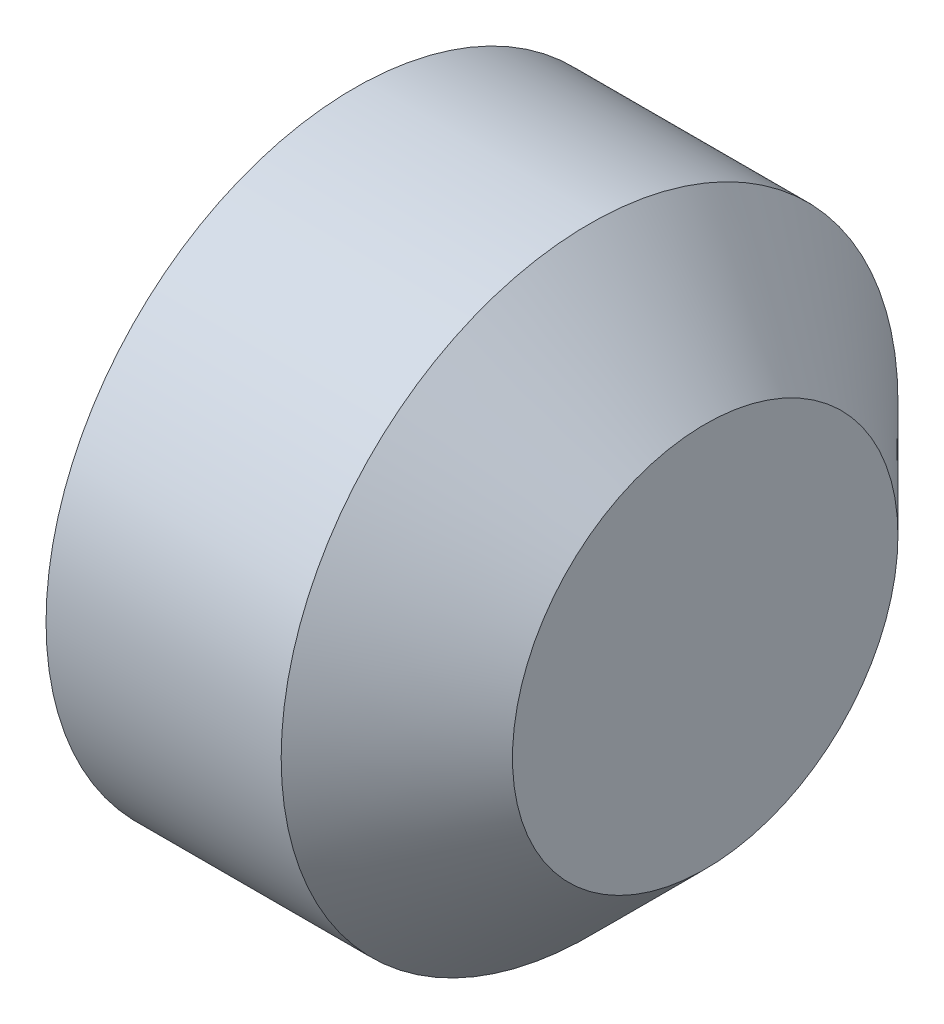
from build123d import *

# Parameters (mm, degrees)
SKETCH_1_W          = 2.5
SKETCH_1_H          = 2
CUT_EXTRUDE_1_DEPTH = 1.5
CHAMFER_1_SIZE      = 0.75
CHAMFER_2_SIZE      = 0.39
CHAMFER_2_SIZE2     = 0.225166605


with BuildPart() as part:
    # Эскиз1 → Повернуть1 (revolve)
    with BuildSketch(Plane(origin=(0, 0, 0), x_dir=(-1, 0, 0), z_dir=(0, 0, -1))):
        with Locations((-1.25, 1)):
            Rectangle(SKETCH_1_W, SKETCH_1_H)
    revolve(axis=Axis((2.5, 0, 0), (-1, 0, 0)))

    # Эскиз2 → Вырез-Вытянуть1 (cut)
    with BuildSketch(Plane.ZY):
        Polygon((1.154700538, 0), (0.577350269, 1), (-0.577350269, 1), (-1.154700538, 0), (-0.577350269, -1), (0.577350269, -1), align=None)
    extrude(amount=-CUT_EXTRUDE_1_DEPTH, mode=Mode.SUBTRACT)

    # Фаска1
    chamfer_1_edges = [part.edges().sort_by_distance(p)[0] for p in [
        (2.5, -2, 0),
    ]]
    chamfer(chamfer_1_edges, length=CHAMFER_1_SIZE)

    # Фаска2
    chamfer_2_edges = [part.edges().sort_by_distance(p)[0] for p in [
        (0, -2, 0),
    ]]
    chamfer_2_side = [part.faces().sort_by_distance(p)[0] for p in [
        (0, -1.943431458, 0),
    ]]
    chamfer(chamfer_2_edges, length=CHAMFER_2_SIZE, length2=CHAMFER_2_SIZE2, reference=chamfer_2_side[0])


solid = part.part
